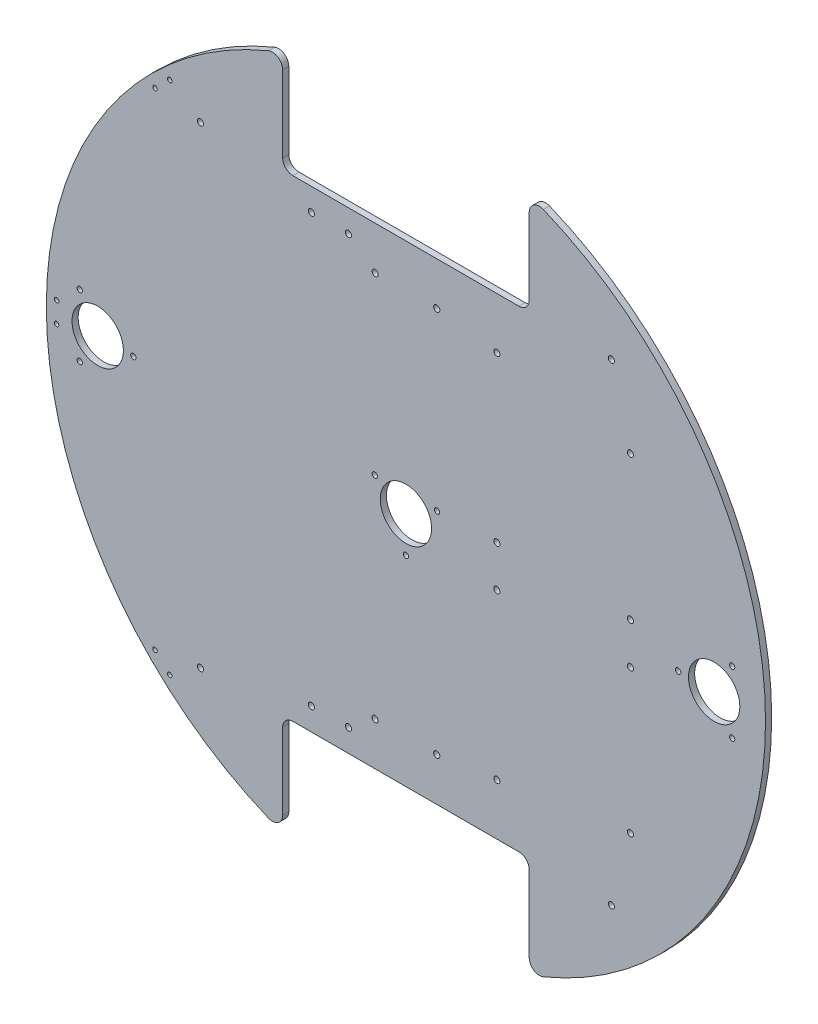
from build123d import *

# Parameters (mm, degrees)
SKETCH_1_R           = 175
EXTRUDE_1_DEPTH      = 3
CUT_EXTRUDE_1_DEPTH  = 3
FILLET_1_R           = 5
FILLET_2_R           = 5
FILLET_3_R           = 5
SKETCH_5_R           = 1.5
CUT_EXTRUDE_4_DEPTH  = 3
SKETCH_10_R          = 12.5
SKETCH_10_R_2        = 1.3
CUT_EXTRUDE_13_DEPTH = 10
SKETCH_14_R          = 1.1
CUT_EXTRUDE_14_DEPTH = 10
SKETCH_12_R          = 1.5
CUT_EXTRUDE_17_DEPTH = 10
SKETCH_13_R          = 1.5
CUT_EXTRUDE_18_DEPTH = 5
SKETCH_15_R          = 1.5
CUT_EXTRUDE_19_DEPTH = 4


with BuildPart() as part:
    # ｽｹｯﾁ1 → ﾎﾞｽ - 押し出し1 (new body)
    with BuildSketch(Plane.XY):
        Circle(SKETCH_1_R)
    extrude(amount=EXTRUDE_1_DEPTH)

    # ｽｹｯﾁ2 → ｶｯﾄ - 押し出し1 (cut)
    with BuildSketch(Plane.XY.offset(3)):
        with BuildLine():
            Line((-60, 115), (0, 115))
            Line((0, 115), (0, 175))
            ThreePointArc((0, 175), (-30.465194158, 172.327803749), (-60, 164.392822228))
            Line((-60, 164.392822228), (-60, 115))
        make_face()
        with BuildLine():
            Line((0, 175), (0, 115))
            Line((0, 115), (60, 115))
            Line((60, 115), (60, 164.392822228))
            ThreePointArc((60, 164.392822228), (30.465194158, 172.327803749), (0, 175))
        make_face()
        with BuildLine():
            Line((0, -175), (0, -115))
            Line((0, -115), (-60, -115))
            Line((-60, -115), (-60, -164.392822228))
            ThreePointArc((-60, -164.392822228), (-30.465194158, -172.327803749), (0, -175))
        make_face()
        with BuildLine():
            Line((60, -115), (0, -115))
            Line((0, -115), (0, -175))
            ThreePointArc((0, -175), (30.465194158, -172.327803749), (60, -164.392822228))
            Line((60, -164.392822228), (60, -115))
        make_face()
    extrude(amount=-CUT_EXTRUDE_1_DEPTH, mode=Mode.SUBTRACT)

    # ﾌｨﾚｯﾄ1
    fillet_1_edges = [part.edges().sort_by_distance(p)[0] for p in [
        (-60, 164.392822228, 1.5),
    ]]
    fillet(fillet_1_edges, radius=FILLET_1_R)

    # ﾌｨﾚｯﾄ2
    fillet_2_edges = [part.edges().sort_by_distance(p)[0] for p in [
        (-60, 115, 1.5),
        (60, 164.392822228, 1.5),
        (60, 115, 1.5),
    ]]
    fillet(fillet_2_edges, radius=FILLET_2_R)

    # ﾌｨﾚｯﾄ3
    fillet_3_edges = [part.edges().sort_by_distance(p)[0] for p in [
        (-60, -115, 1.5),
        (60, -115, 1.5),
        (60, -164.392822228, 1.5),
        (-60, -164.392822228, 1.5),
    ]]
    fillet(fillet_3_edges, radius=FILLET_3_R)

    # ｽｹｯﾁ5 → ｶｯﾄ - 押し出し4 (cut)
    with BuildSketch(Plane.XY.offset(3)):
        with Locations((-100, -115)):
            Circle(SKETCH_5_R)
        with Locations((100, -115)):
            Circle(SKETCH_5_R)
        with Locations((100, 115)):
            Circle(SKETCH_5_R)
        with Locations((-100, 115)):
            Circle(SKETCH_5_R)
    extrude(amount=-CUT_EXTRUDE_4_DEPTH, mode=Mode.SUBTRACT)

    # ｽｹｯﾁ10 → ｶｯﾄ - 押し出し13 (cut)
    with BuildSketch(Plane.XY.offset(3)):
        with Locations((-150, 0)):
            Circle(SKETCH_10_R)
        with Locations((150, 0)):
            Circle(SKETCH_10_R)
        Circle(SKETCH_10_R)
        with Locations((132.5, 0)):
            Circle(SKETCH_10_R_2)
        with Locations((158.75, 15.155444566)):
            Circle(SKETCH_10_R_2)
        with Locations((158.75, -15.155444566)):
            Circle(SKETCH_10_R_2)
        with Locations((-15.155444566, 8.75)):
            Circle(SKETCH_10_R_2)
        with Locations((15.155444566, 8.75)):
            Circle(SKETCH_10_R_2)
        with Locations((0, -17.5)):
            Circle(SKETCH_10_R_2)
        with Locations((-158.75, 15.155444566)):
            Circle(SKETCH_10_R_2)
        with Locations((-158.75, -15.155444566)):
            Circle(SKETCH_10_R_2)
        with Locations((-132.632898389, 0)):
            Circle(SKETCH_10_R_2)
    extrude(amount=-CUT_EXTRUDE_13_DEPTH, mode=Mode.SUBTRACT)

    # ｽｹｯﾁ14 → ｶｯﾄ - 押し出し14 (cut)
    with BuildSketch(Plane.XY.offset(3)):
        with Locations((-170, 5)):
            Circle(SKETCH_14_R)
        with Locations((-170, -5)):
            Circle(SKETCH_14_R)
        with Locations((-114.933514447, 125.360628815)):
            Circle(SKETCH_14_R)
        with Locations((-122.102620524, 118.388977786)):
            Circle(SKETCH_14_R)
        with Locations((-122.102620524, -118.388977786)):
            Circle(SKETCH_14_R)
        with Locations((-114.933514447, -125.360628815)):
            Circle(SKETCH_14_R)
    extrude(amount=-CUT_EXTRUDE_14_DEPTH, mode=Mode.SUBTRACT)

    # ｽｹｯﾁ12 → ｶｯﾄ - 押し出し17 (cut)
    with BuildSketch(Plane.XY.offset(3)):
        with Locations((-15, 94)):
            Circle(SKETCH_12_R)
        with Locations((15, 94)):
            Circle(SKETCH_12_R)
        with Locations((-15, -94)):
            Circle(SKETCH_12_R)
        with Locations((15, -94)):
            Circle(SKETCH_12_R)
    extrude(amount=-CUT_EXTRUDE_17_DEPTH, mode=Mode.SUBTRACT)

    # ｽｹｯﾁ13 → ｶｯﾄ - 押し出し18 (cut)
    with BuildSketch(Plane.XY.offset(3)):
        with Locations((-28, -104)):
            Circle(SKETCH_13_R)
        with Locations((-46, -104)):
            Circle(SKETCH_13_R)
        with Locations((-46, 104)):
            Circle(SKETCH_13_R)
        with Locations((-28, 104)):
            Circle(SKETCH_13_R)
    extrude(amount=-CUT_EXTRUDE_18_DEPTH, mode=Mode.SUBTRACT)

    # ｽｹｯﾁ15 → ｶｯﾄ - 押し出し19 (cut, through all)
    with BuildSketch(Plane.XY.offset(3)):
        with Locations((44.252990552, 10)):
            Circle(SKETCH_15_R)
        with Locations((44.252990552, 90)):
            Circle(SKETCH_15_R)
        with Locations((109.252990552, 10)):
            Circle(SKETCH_15_R)
        with Locations((109.252990552, 80)):
            Circle(SKETCH_15_R)
        with Locations((44.252990552, -10)):
            Circle(SKETCH_15_R)
        with Locations((109.252990552, -10)):
            Circle(SKETCH_15_R)
        with Locations((44.252990552, -90)):
            Circle(SKETCH_15_R)
        with Locations((109.252990552, -80)):
            Circle(SKETCH_15_R)
    extrude(amount=-CUT_EXTRUDE_19_DEPTH, mode=Mode.SUBTRACT)


solid = part.part
